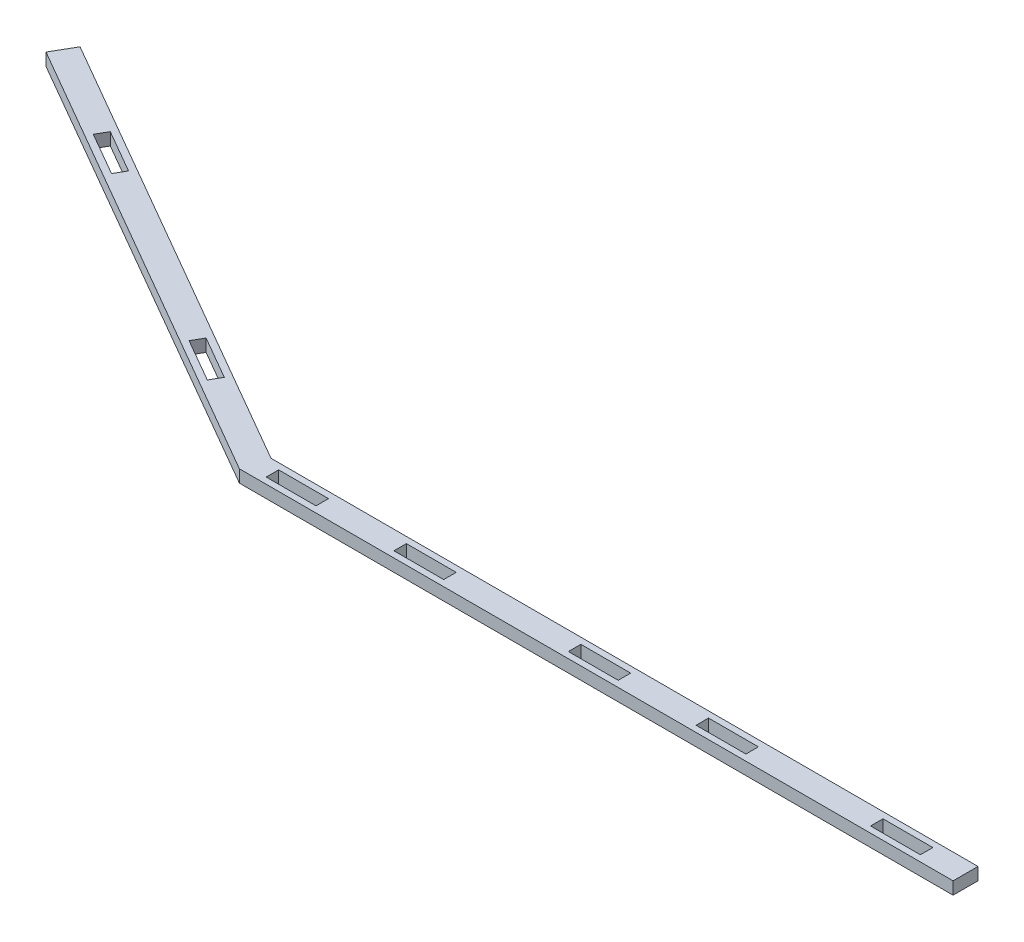
from build123d import *

# Parameters (mm, degrees)
SKETCH4_W           = 25.4
SKETCH4_H           = 6.35
BOSS_EXTRUDE2_DEPTH = 6.35


with BuildPart() as part:
    # Sketch4 → Boss-Extrude2 (new body)
    with BuildSketch(Plane(origin=(0, 0, 0), x_dir=(1, 0, 0), z_dir=(0, 1, 0))):
        Polygon((-596.849633079, 128.276111157), (-590.499633079, 139.274633785), (-360.267413785, 6.35), (0, 6.35), (0, -6.35), (-363.670368529, -6.35), align=None)
        Polygon((-548.51841191, 104.038241814), (-526.521366654, 91.338241814), (-523.346366654, 96.837503128), (-545.34341191, 109.537503128), align=None, mode=Mode.SUBTRACT)
        Polygon((-433.033924315, 37.363241814), (-411.036879059, 24.663241814), (-407.861879059, 30.162503128), (-429.858924315, 42.862503128), align=None, mode=Mode.SUBTRACT)
        with Locations((-340.498292116, 0)):
            Rectangle(SKETCH4_W, SKETCH4_H, mode=Mode.SUBTRACT)
        with Locations((-275.418975234, 0)):
            Rectangle(SKETCH4_W, SKETCH4_H, mode=Mode.SUBTRACT)
        with Locations((-186.518975234, 0)):
            Rectangle(SKETCH4_W, SKETCH4_H, mode=Mode.SUBTRACT)
        with Locations((-121.439658352, 0)):
            Rectangle(SKETCH4_W, SKETCH4_H, mode=Mode.SUBTRACT)
        with Locations((-32.539658352, 0)):
            Rectangle(SKETCH4_W, SKETCH4_H, mode=Mode.SUBTRACT)
    extrude(amount=BOSS_EXTRUDE2_DEPTH)


solid = part.part
